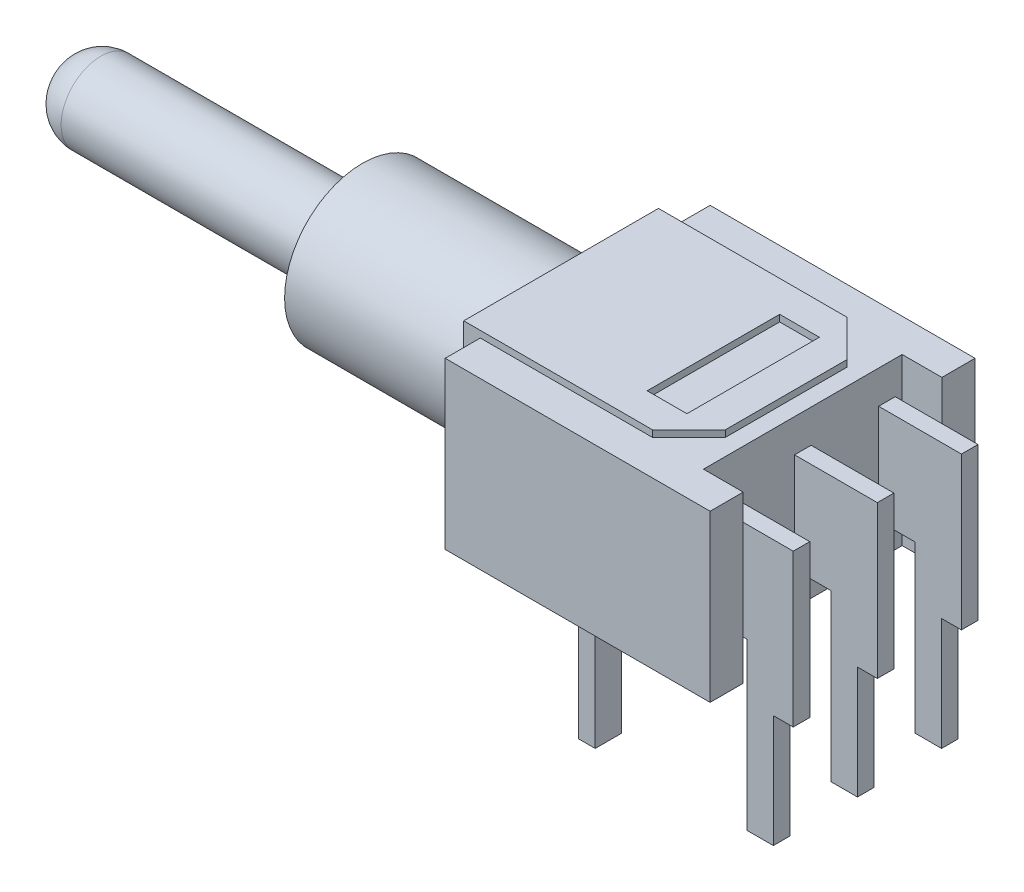
from build123d import *

# Parameters (mm, degrees)
BOSS_EXTRU_1_DEPTH         = 5
BOSS_EXTRU_2_DEPTH         = 0.25
BOSS_EXTRU_3_DEPTH         = 2.94
ESQUISSE6_W                = 4.28
ESQUISSE6_H                = 4
ENL_V_MAT_EXTRU_1_DEPTH    = 0.7
ESQUISSE7_R                = 2.35
ESQUISSE7_R_2              = 1.85
BOSS_EXTRU_4_DEPTH         = 6
ESQUISSE8_R                = 1.2
BOSS_EXTRU_5_DEPTH         = 15
CONG_1_R                   = 1.1
ESQUISSE9_W                = 1.2
ESQUISSE9_H                = 4
BOSS_EXTRU_6_DEPTH         = 0.2
R_P_TITION_LIN_AIRE1_COUNT = 2
R_P_TITION_LIN_AIRE1_PITCH = 2.54
R_P_TITION_LIN_AIRE2_COUNT = 2
R_P_TITION_LIN_AIRE2_PITCH = 2.54


with BuildPart() as part:
    # Esquisse1 → Boss.-Extru.1 (new body)
    with BuildSketch(Plane(origin=(0, 0, 0), x_dir=(1, 0, 0), z_dir=(0, 1, 0))):
        Polygon((0, 0), (8, 0), (8, 1), (6.8, 1), (6.8, 7), (8, 7), (8, 8), (0, 8), align=None)
    extrude(amount=BOSS_EXTRU_1_DEPTH)

    # Esquisse4 → Boss.-Extru.2 (add, symmetric)
    with BuildSketch(Plane.XY.offset(-4)):
        Polygon((6.8, 4), (6.8, 1), (7.9, 1), (7.9, -4), (8.7, -4), (8.7, -0.6), (9.3, -0.6), (9.3, 4), align=None)
    boss_extru_2 = extrude(amount=BOSS_EXTRU_2_DEPTH, both=True)

    # Esquisse5 → Boss.-Extru.3 (add, symmetric)
    with BuildSketch(Plane.XY.offset(-4)):
        with BuildLine():
            Line((0, 5.2), (0, 0))
            Line((0, 0), (2.77, 0))
            ThreePointArc((2.77, 0), (3.264974747, -0.205025253), (3.47, -0.7))
            Line((3.47, -0.7), (3.47, -4))
            Line((3.47, -4), (2.97, -4))
            Line((2.97, -4), (2.97, -0.7))
            ThreePointArc((2.97, -0.7), (2.911421356, -0.558578644), (2.77, -0.5))
            Line((2.77, -0.5), (-0.2, -0.5))
            ThreePointArc((-0.2, -0.5), (-0.412132034, -0.412132034), (-0.5, -0.2))
            Line((-0.5, -0.2), (-0.5, 5.2))
            Line((-0.5, 5.2), (0, 5.2))
        make_face()
    extrude(amount=BOSS_EXTRU_3_DEPTH, both=True)

    # Esquisse6 → Enlèv. mat.-Extru.1 (cut)
    with BuildSketch(Plane(origin=(3.47, 0, 0), x_dir=(0, 0, -1), z_dir=(1, 0, 0))):
        with Locations((4, -2)):
            Rectangle(ESQUISSE6_W, ESQUISSE6_H)
    extrude(amount=-ENL_V_MAT_EXTRU_1_DEPTH, mode=Mode.SUBTRACT)

    # Esquisse7 → Boss.-Extru.4 (add)
    with BuildSketch(Plane.ZY.offset(0.5)):
        with Locations(Location((-4, 2.5, 0), (0, 0, 90))):  # turned: the seam where the file's is
            Circle(ESQUISSE7_R)
        with Locations(Location((-4, 2.5, 0), (0, 0, 270))):  # turned: the seam where the file's is
            Circle(ESQUISSE7_R_2, mode=Mode.SUBTRACT)
    extrude(amount=BOSS_EXTRU_4_DEPTH)

    # Esquisse8 → Boss.-Extru.5 (add)
    with BuildSketch(Plane.ZY.offset(0.5)):
        with Locations(Location((-4, 2.5, 0), (0, 0, 90))):  # turned: the seam where the file's is
            Circle(ESQUISSE8_R)
    extrude(amount=BOSS_EXTRU_5_DEPTH)

    # Congé1
    cong_1_edges = [part.edges().sort_by_distance(p)[0] for p in [
        (-15.5, 1.3, -4),
    ]]
    fillet(cong_1_edges, radius=CONG_1_R)

    # Esquisse9 → Boss.-Extru.6 (add)
    with BuildSketch(Plane(origin=(0, 5, 0), x_dir=(1, 0, 0), z_dir=(0, 1, 0))):
        Polygon((0, 6.94), (5.2, 6.94), (6.3, 5.84), (6.3, 2.16), (5.2, 1.06), (0, 1.06), align=None)
        with Locations((4.7, 4)):
            Rectangle(ESQUISSE9_W, ESQUISSE9_H, mode=Mode.SUBTRACT)
    extrude(amount=BOSS_EXTRU_6_DEPTH)

    # Répétition linéaire1: Boss.-Extru.2 ×2
    with Locations(*[(0, 0, -i * R_P_TITION_LIN_AIRE1_PITCH) for i in range(1, R_P_TITION_LIN_AIRE1_COUNT)]):
        add(boss_extru_2)

    # Répétition linéaire2: Boss.-Extru.2 ×2
    with Locations(*[(0, 0, i * R_P_TITION_LIN_AIRE2_PITCH) for i in range(1, R_P_TITION_LIN_AIRE2_COUNT)]):
        add(boss_extru_2)


solid = part.part
